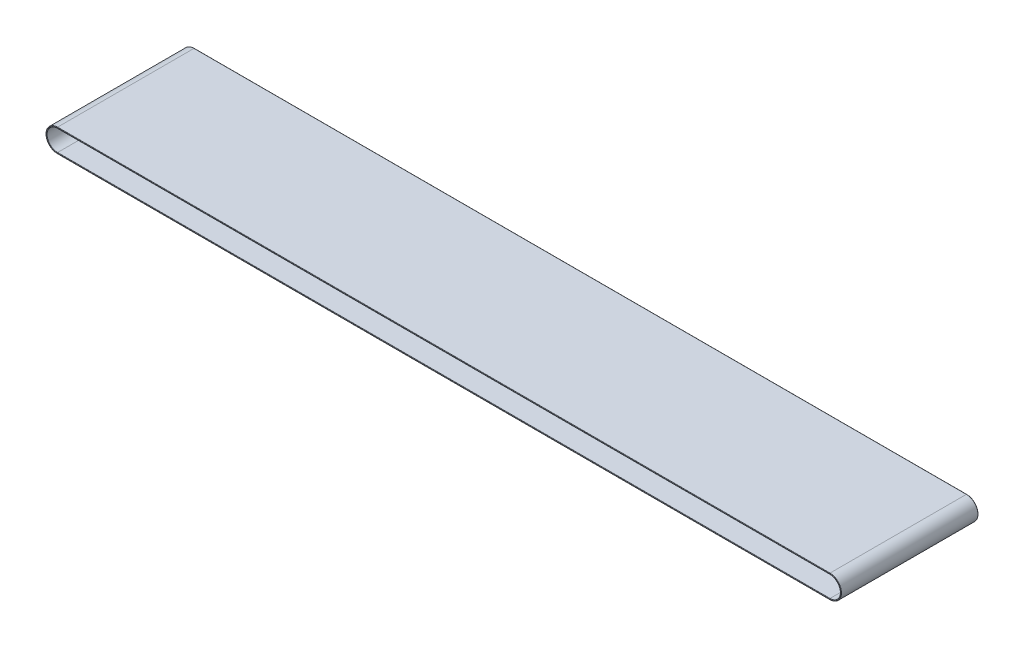
from build123d import *

# Parameters (mm, degrees)
BOSS_EXTRUDE1_DEPTH = 50.673
FILLET1_R           = 0.127


with BuildPart() as part:
    # Sketch2 → Boss-Extrude1 (new body)
    with BuildSketch(Plane.XY):
        with BuildLine():
            Line((-142.875, 4.2545), (142.875, 4.2545))
            ThreePointArc((142.875, 4.2545), (147.1295, 0), (142.875, -4.2545))
            Line((142.875, -4.2545), (-142.875, -4.2545))
            ThreePointArc((-142.875, -4.2545), (-147.1295, 0), (-142.875, 4.2545))
        make_face()
        with BuildLine():
            ThreePointArc((142.875, -3.8735), (146.7485, 0), (142.875, 3.8735))
            Line((142.875, 3.8735), (-142.875, 3.8735))
            ThreePointArc((-142.875, 3.8735), (-146.7485, 0), (-142.875, -3.8735))
            Line((-142.875, -3.8735), (142.875, -3.8735))
        make_face(mode=Mode.SUBTRACT)
    extrude(amount=BOSS_EXTRUDE1_DEPTH)

    # Fillet1
    fillet1_edges = [part.edges().sort_by_distance(p)[0] for p in [
        (147.1295, 0, 0),
        (0, -4.2545, 0),
        (-147.1295, 0, 0),
        (0, 4.2545, 0),
        (0, -3.8735, 50.673),
        (0, 3.8735, 0),
        (-146.7485, 0, 0),
        (0, -3.8735, 0),
        (146.7485, 0, 0),
        (-146.7485, 0, 50.673),
        (0, 3.8735, 50.673),
        (0, 4.2545, 50.673),
        (-147.1295, 0, 50.673),
        (0, -4.2545, 50.673),
        (147.1295, 0, 50.673),
        (146.7485, 0, 50.673),
    ]]
    fillet(fillet1_edges, radius=FILLET1_R)


solid = part.part
